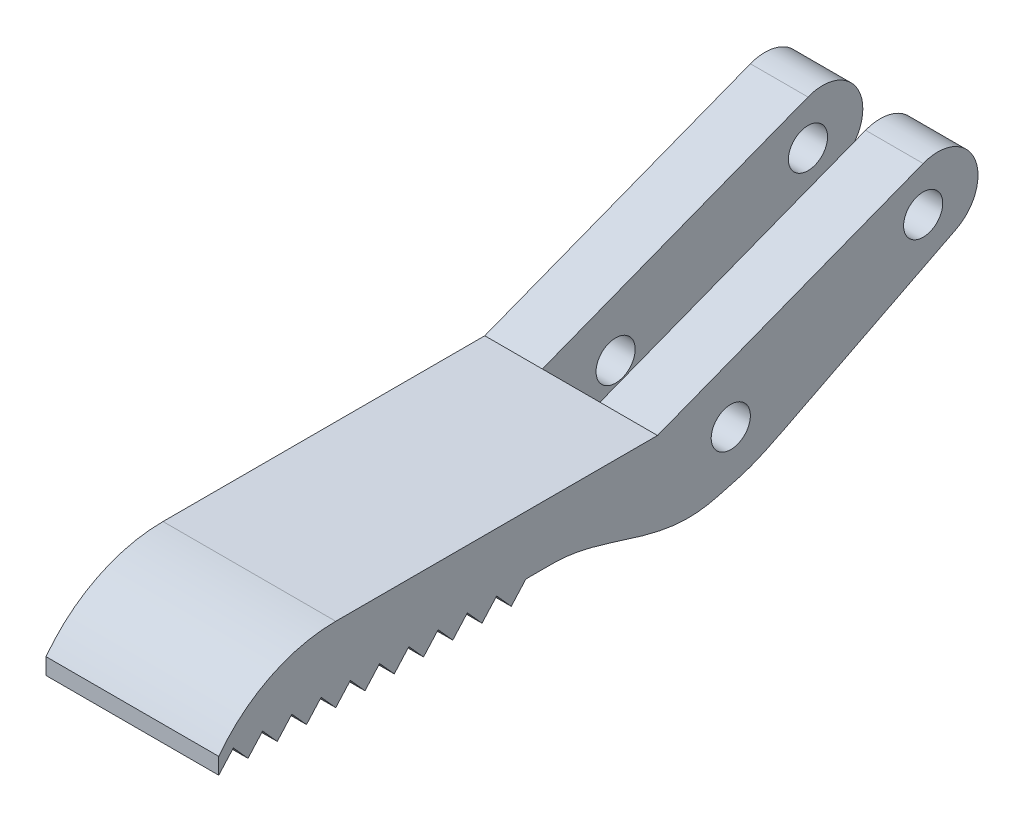
from build123d import *

# Parameters (mm, degrees)
BOSS_EXTRUDE1_DEPTH = 2.54
BOSS_EXTRUDE2_DEPTH = 8.08
BOSS_EXTRUDE3_START = -5
BOSS_EXTRUDE3_DEPTH = 5
BOSS_EXTRUDE4_START = 5
BOSS_EXTRUDE4_DEPTH = 5
SKETCH8_R           = 1.7
CUT_EXTRUDE1_DEPTH  = 543.252698287


with BuildPart() as part:
    # Sketch1 → Boss-Extrude1 (new body)
    with BuildSketch(Plane(origin=(14.957777778, 0, 0), x_dir=(0, 0, -1), z_dir=(1, 0, 0))):
        with BuildLine():
            Line((-496.113012561, 30.744895578), (-521.513012561, 30.744895578))
            Line((-521.513012561, 30.744895578), (-521.513012561, 25.664895578))
            Line((-521.513012561, 25.664895578), (-496.113012561, 25.664895578))
            ThreePointArc((-496.113012561, 25.664895578), (-494.404850963, 26.325059427), (-493.584615771, 27.962388527))
            Line((-493.584615771, 27.962388527), (-480.88314332, 33.756493956))
            ThreePointArc((-480.88314332, 33.756493956), (-477.098018282, 36.879077411), (-481.937324449, 36.067403333))
            Line((-481.937324449, 36.067403333), (-494.6387969, 30.273297904))
            ThreePointArc((-494.6387969, 30.273297904), (-495.339107499, 30.624124991), (-496.113012561, 30.744895578))
        make_face()
    extrude(amount=-BOSS_EXTRUDE1_DEPTH)

    # Sketch2 → Boss-Extrude2 (add)
    with BuildSketch(Plane(origin=(14.957777778, 0, 0), x_dir=(0, 0, -1), z_dir=(1, 0, 0))):
        with BuildLine():
            Line((-513.904615771, 25.664895578), (-502.474615771, 25.664895578))
            Line((-502.474615771, 25.664895578), (-502.474615771, 30.744895578))
            Line((-502.474615771, 30.744895578), (-530.414615771, 30.744895578))
            ThreePointArc((-530.414615771, 30.744895578), (-536.094228434, 29.404120904), (-540.574615771, 25.664895578))
            Line((-540.574615771, 25.664895578), (-540.574615771, 24.244992412))
            Line((-540.574615771, 24.244992412), (-539.304615771, 25.664895578))
            Line((-539.304615771, 25.664895578), (-538.034615771, 24.244992412))
            Line((-538.034615771, 24.244992412), (-536.764615771, 25.664895578))
            Line((-536.764615771, 25.664895578), (-535.494615771, 24.244992412))
            Line((-535.494615771, 24.244992412), (-534.224615771, 25.664895578))
            Line((-534.224615771, 25.664895578), (-532.954615771, 24.244992412))
            Line((-532.954615771, 24.244992412), (-531.684615771, 25.664895578))
            Line((-531.684615771, 25.664895578), (-530.414615771, 24.244992412))
            Line((-530.414615771, 24.244992412), (-529.144615771, 25.664895578))
            Line((-529.144615771, 25.664895578), (-527.874615771, 24.244992412))
            Line((-527.874615771, 24.244992412), (-526.604615771, 25.664895578))
            Line((-526.604615771, 25.664895578), (-525.334615771, 24.244992412))
            Line((-525.334615771, 24.244992412), (-524.064615771, 25.664895578))
            Line((-524.064615771, 25.664895578), (-522.794615771, 24.244992412))
            Line((-522.794615771, 24.244992412), (-521.524615771, 25.664895578))
            Line((-521.524615771, 25.664895578), (-520.254615771, 24.244992412))
            Line((-520.254615771, 24.244992412), (-518.984615771, 25.664895578))
            Line((-518.984615771, 25.664895578), (-517.714615771, 24.244992412))
            Line((-517.714615771, 24.244992412), (-516.444615771, 25.664895578))
            Line((-516.444615771, 25.664895578), (-515.174615771, 24.244992412))
            Line((-515.174615771, 24.244992412), (-513.904615771, 25.664895578))
        make_face()
    extrude(amount=BOSS_EXTRUDE2_DEPTH)

    # Sketch7 → Boss-Extrude3 (add)
    with BuildSketch(Plane(origin=(14.957777778, 0, 0), x_dir=(0, 0, -1), z_dir=(1, 0, 0)).offset(BOSS_EXTRUDE3_START)):
        with BuildLine():
            Line((-502.474615771, 30.744895578), (-479.408927659, 39.66518211))
            ThreePointArc((-479.408927659, 39.66518211), (-474.949798497, 37.8260107), (-476.562112461, 33.279932386))
            Line((-476.562112461, 33.279932386), (-491.562112461, 25.664895578))
            add(Edge.make_bspline(
                [(-491.562112461, 25.664895578), (-494.237137805, 24.306867814), (-495.170436648, 24.128959325), (-502.31030057, 22.103673482), (-507.062112461, 25.664895578), (-511.562112461, 25.664895578)],
                knots=[0, 0, 0, 0, 0.24107407, 0.34107407, 1, 1, 1, 1], degree=3))
            Line((-511.562112461, 25.664895578), (-513.904615771, 25.664895578))
            Line((-513.904615771, 25.664895578), (-515.174615771, 24.244992412))
            Line((-515.174615771, 24.244992412), (-516.444615771, 25.664895578))
            Line((-516.444615771, 25.664895578), (-517.714615771, 24.244992412))
            Line((-517.714615771, 24.244992412), (-518.984615771, 25.664895578))
            Line((-518.984615771, 25.664895578), (-520.254615771, 24.244992412))
            Line((-520.254615771, 24.244992412), (-521.524615771, 25.664895578))
            Line((-521.524615771, 25.664895578), (-522.794615771, 24.244992412))
            Line((-522.794615771, 24.244992412), (-524.064615771, 25.664895578))
            Line((-524.064615771, 25.664895578), (-525.334615771, 24.244992412))
            Line((-525.334615771, 24.244992412), (-526.604615771, 25.664895578))
            Line((-526.604615771, 25.664895578), (-527.874615771, 24.244992412))
            Line((-527.874615771, 24.244992412), (-529.144615771, 25.664895578))
            Line((-529.144615771, 25.664895578), (-530.414615771, 24.244992412))
            Line((-530.414615771, 24.244992412), (-531.684615771, 25.664895578))
            Line((-531.684615771, 25.664895578), (-532.954615771, 24.244992412))
            Line((-532.954615771, 24.244992412), (-534.224615771, 25.664895578))
            Line((-534.224615771, 25.664895578), (-535.494615771, 24.244992412))
            Line((-535.494615771, 24.244992412), (-536.764615771, 25.664895578))
            Line((-536.764615771, 25.664895578), (-538.034615771, 24.244992412))
            Line((-538.034615771, 24.244992412), (-539.304615771, 25.664895578))
            Line((-539.304615771, 25.664895578), (-540.574615771, 24.244992412))
            Line((-540.574615771, 24.244992412), (-540.574615771, 25.664895578))
            ThreePointArc((-540.574615771, 25.664895578), (-536.094228434, 29.404120904), (-530.414615771, 30.744895578))
            Line((-530.414615771, 30.744895578), (-502.474615771, 30.744895578))
        make_face()
    extrude(amount=BOSS_EXTRUDE3_DEPTH)

    # Sketch7_2 → Boss-Extrude4 (add)
    with BuildSketch(Plane(origin=(14.957777778, 0, 0), x_dir=(0, 0, -1), z_dir=(1, 0, 0)).offset(BOSS_EXTRUDE4_START)):
        with BuildLine():
            Line((-502.474615771, 25.664895578), (-502.474615771, 30.744895578))
            Line((-502.474615771, 30.744895578), (-530.414615771, 30.744895578))
            ThreePointArc((-530.414615771, 30.744895578), (-536.094228434, 29.404120904), (-540.574615771, 25.664895578))
            Line((-540.574615771, 25.664895578), (-540.574615771, 24.244992412))
            Line((-540.574615771, 24.244992412), (-539.304615771, 25.664895578))
            Line((-539.304615771, 25.664895578), (-538.034615771, 24.244992412))
            Line((-538.034615771, 24.244992412), (-536.764615771, 25.664895578))
            Line((-536.764615771, 25.664895578), (-535.494615771, 24.244992412))
            Line((-535.494615771, 24.244992412), (-534.224615771, 25.664895578))
            Line((-534.224615771, 25.664895578), (-532.954615771, 24.244992412))
            Line((-532.954615771, 24.244992412), (-531.684615771, 25.664895578))
            Line((-531.684615771, 25.664895578), (-530.414615771, 24.244992412))
            Line((-530.414615771, 24.244992412), (-529.144615771, 25.664895578))
            Line((-529.144615771, 25.664895578), (-527.874615771, 24.244992412))
            Line((-527.874615771, 24.244992412), (-526.604615771, 25.664895578))
            Line((-526.604615771, 25.664895578), (-525.334615771, 24.244992412))
            Line((-525.334615771, 24.244992412), (-524.064615771, 25.664895578))
            Line((-524.064615771, 25.664895578), (-522.794615771, 24.244992412))
            Line((-522.794615771, 24.244992412), (-521.524615771, 25.664895578))
            Line((-521.524615771, 25.664895578), (-520.254615771, 24.244992412))
            Line((-520.254615771, 24.244992412), (-518.984615771, 25.664895578))
            Line((-518.984615771, 25.664895578), (-517.714615771, 24.244992412))
            Line((-517.714615771, 24.244992412), (-516.444615771, 25.664895578))
            Line((-516.444615771, 25.664895578), (-515.174615771, 24.244992412))
            Line((-515.174615771, 24.244992412), (-513.904615771, 25.664895578))
            Line((-513.904615771, 25.664895578), (-511.562112461, 25.664895578))
            Line((-511.562112461, 25.664895578), (-502.474615771, 25.664895578))
        make_face()
        with BuildLine():
            Line((-479.408927659, 39.66518211), (-502.474615771, 30.744895578))
            Line((-502.474615771, 30.744895578), (-502.474615771, 25.664895578))
            Line((-502.474615771, 25.664895578), (-511.562112461, 25.664895578))
            add(Edge.make_bspline(
                [(-491.562112461, 25.664895578), (-494.237137805, 24.306867814), (-495.170436648, 24.128959325), (-502.31030057, 22.103673482), (-507.062112461, 25.664895578), (-511.562112461, 25.664895578)],
                knots=[0, 0, 0, 0, 0.24107407, 0.34107407, 1, 1, 1, 1], degree=3))
            Line((-491.562112461, 25.664895578), (-476.562112461, 33.279932386))
            ThreePointArc((-476.562112461, 33.279932386), (-474.949798497, 37.8260107), (-479.408927659, 39.66518211))
        make_face()
    extrude(amount=BOSS_EXTRUDE4_DEPTH)

    # Sketch8 → Cut-Extrude1 (cut, through all)
    with BuildSketch(Plane(origin=(9.957777778, 0, 0), x_dir=(0, 0, -1), z_dir=(1, 0, 0))):
        with Locations((-496.113012561, 28.204895578)):
            Circle(SKETCH8_R)
        with Locations((-479.408927659, 35.824896282)):
            Circle(SKETCH8_R)
    extrude(amount=CUT_EXTRUDE1_DEPTH, mode=Mode.SUBTRACT)


solid = part.part
